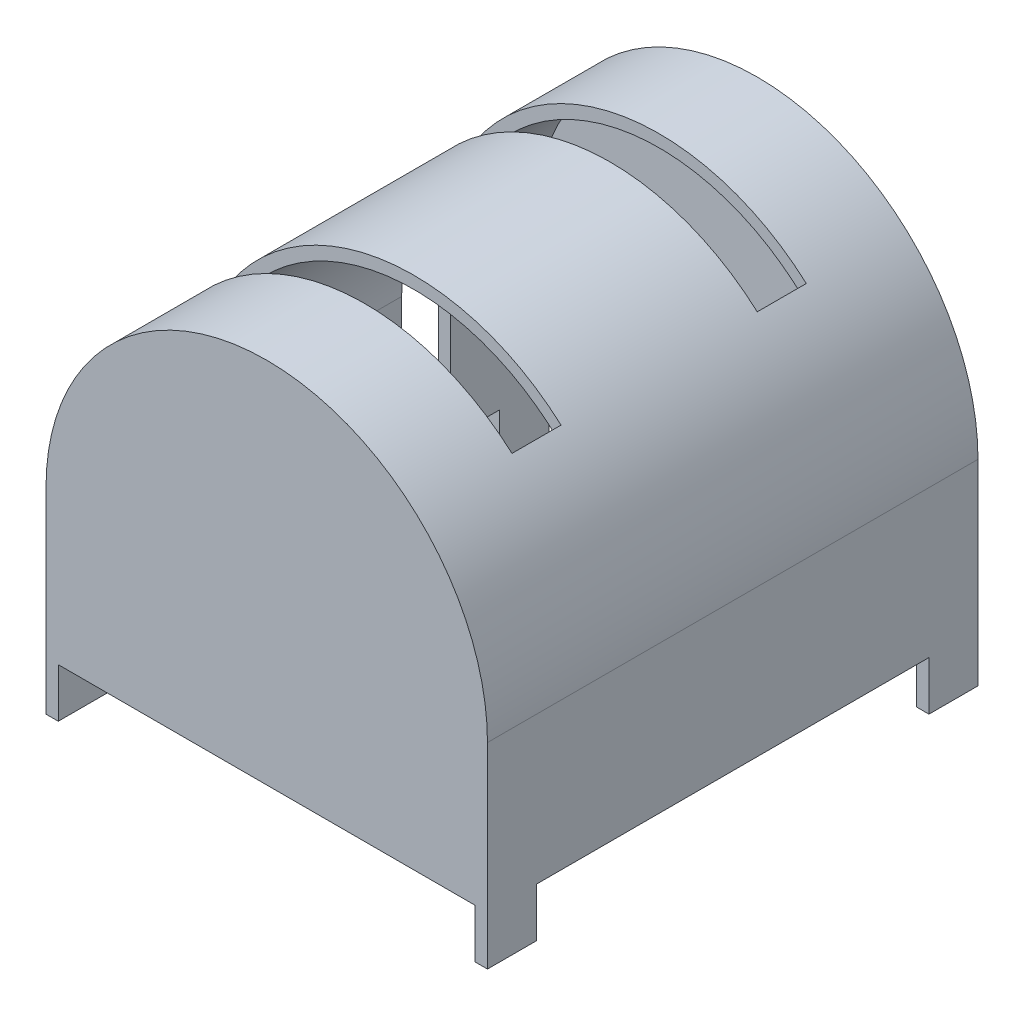
from build123d import *

# Parameters (mm, degrees)
SKETCH1_W           = 90
SKETCH1_H           = 100
SKETCH1_W_2         = 85
SKETCH1_H_2         = 95
BOSS_EXTRUDE1_DEPTH = 30
SKETCH2_W           = 2.5
SKETCH2_H           = 10
BOSS_EXTRUDE2_DEPTH = 10
REVOLVE1_ANGLE      = 180
CUT_EXTRUDE1_DEPTH  = 101.747208398


with BuildPart() as part:
    # Sketch1 → Boss-Extrude1 (new body)
    with BuildSketch(Plane(origin=(0, 0, 0), x_dir=(1, 0, 0), z_dir=(0, 1, 0))):
        Rectangle(SKETCH1_W, SKETCH1_H)
        Rectangle(SKETCH1_W_2, SKETCH1_H_2, mode=Mode.SUBTRACT)
    extrude(amount=BOSS_EXTRUDE1_DEPTH)

    # Sketch2 → Boss-Extrude2 (add)
    with BuildSketch(Plane.XZ):
        Polygon((-42.5, 47.5), (-42.5, 50), (-45, 50), (-45, 40), (-42.5, 40), align=None)
        Polygon((42.5, 47.5), (42.5, 50), (45, 50), (45, 40), (42.5, 40), align=None)
        Polygon((-42.5, -47.5), (-42.5, -40), (-45, -40), (-45, -50), (-42.5, -50), align=None)
        with Locations((43.75, -45)):
            Rectangle(SKETCH2_W, SKETCH2_H)
    extrude(amount=BOSS_EXTRUDE2_DEPTH)

    # Sketch4 → Revolve1 (revolve)
    with BuildSketch(Plane(origin=(0, 30, 0), x_dir=(1, 0, 0), z_dir=(0, 1, 0))):
        Polygon((45, 50), (45, -50), (0, -50), (0, -47.5), (42.5, -47.5), (42.5, 47.5), (0, 47.5), (0, 50), align=None)
    revolve(axis=Axis((0, 30, -57.663927553), (0, 0, 1)), revolution_arc=REVOLVE1_ANGLE)

    # Sketch5 → Cut-Extrude1 (cut, through all)
    with BuildSketch(Plane(origin=(0, 0, 0), x_dir=(1, 0, 0), z_dir=(0, 1, 0))):
        Polygon((30, 30), (-90, 30), (-90, -30), (30, -30), (30, -20), (-80, -20), (-80, -10), (-80, 10), (-80, 20), (30, 20), align=None)
    extrude(amount=CUT_EXTRUDE1_DEPTH, mode=Mode.SUBTRACT)


solid = part.part
